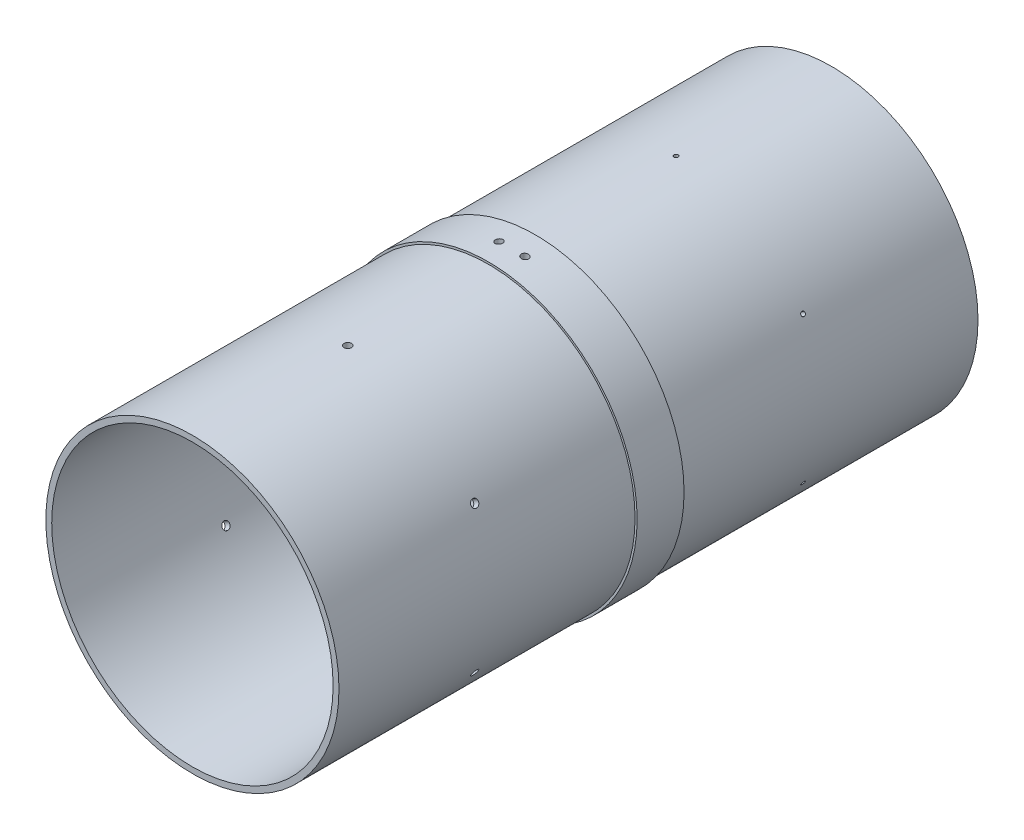
from build123d import *

# Parameters (mm, degrees)
SKETCH1_R                            = 79.375
SKETCH1_R_2                          = 76.2
BOSS_EXTRUDE1_DEPTH                  = 346.075
SKETCH2_R                            = 80.518
SKETCH2_R_2                          = 79.375
BOSS_EXTRUDE2_DEPTH                  = 12.7
F_5_32_0_15625_DIAMETER_HOLE1_REACH  = 393.49
F_5_32_0_15625_DIAMETER_HOLE1_BORE_R = 1.984375
F_4_40_TAPPED_HOLE1_REACH            = 391.637
F_4_40_TAPPED_HOLE1_BORE_R           = 1.1303
CIRPATTERN1_COUNT                    = 6
F_10_32_TAPPED_HOLE1_REACH           = 391.637
F_10_32_TAPPED_HOLE1_BORE_R          = 2.0193
CIRPATTERN2_COUNT                    = 6


with BuildPart() as part:
    # Sketch1 → Boss-Extrude1 (new body)
    with BuildSketch(Plane.XY):
        Circle(SKETCH1_R)
        Circle(SKETCH1_R_2, mode=Mode.SUBTRACT)
    extrude(amount=BOSS_EXTRUDE1_DEPTH)

    # Sketch2 → Boss-Extrude2 (add, symmetric)
    with BuildSketch(Plane.XY.offset(173.0375)):
        Circle(SKETCH2_R)
        Circle(SKETCH2_R_2, mode=Mode.SUBTRACT)
    extrude(amount=BOSS_EXTRUDE2_DEPTH, both=True)

    # 5/32 (0.15625) Diameter Hole1 bore → 5/32 (0.15625) Diameter Hole1 (cut, up to next)
    with BuildSketch(Plane(origin=(7.017606095, 80.211604701, 0), x_dir=(0, 0, 1), z_dir=(0.08715574274765156, 0.9961946980917461, 0)), mode=Mode.PRIVATE) as f_5_32_0_15625_diameter_hole1_sk1:
        with Locations((173.0375, 0)):
            Circle(F_5_32_0_15625_DIAMETER_HOLE1_BORE_R)
    f_5_32_0_15625_diameter_hole1_tool1 = extrude(f_5_32_0_15625_diameter_hole1_sk1.sketch, amount=-F_5_32_0_15625_DIAMETER_HOLE1_REACH, mode=Mode.PRIVATE) & part.part
    f_5_32_0_15625_diameter_hole1 = f_5_32_0_15625_diameter_hole1_tool1.solids().sort_by_distance((7.017606, 80.211605, 173.0375))[0]
    add(f_5_32_0_15625_diameter_hole1, mode=Mode.SUBTRACT)

    # Mirror1: 5/32 (0.15625) Diameter Hole1 across plane
    add(f_5_32_0_15625_diameter_hole1.mirror(Plane(origin=(0, 0, 0), x_dir=(0, 0, 1), z_dir=(1, 0, 0))), mode=Mode.SUBTRACT)

    # #4-40 Tapped Hole1 bore → #4-40 Tapped Hole1 (cut, up to next)
    with BuildSketch(Plane(origin=(0, 79.375, 0), x_dir=(1, 0, 0), z_dir=(0, 1, 0)), mode=Mode.PRIVATE) as f_4_40_tapped_hole1_sk1:
        with Locations((0, -84.1375)):
            Circle(F_4_40_TAPPED_HOLE1_BORE_R)
    f_4_40_tapped_hole1_tool1 = extrude(f_4_40_tapped_hole1_sk1.sketch, amount=-F_4_40_TAPPED_HOLE1_REACH, mode=Mode.PRIVATE) & part.part
    f_4_40_tapped_hole1 = f_4_40_tapped_hole1_tool1.solids().sort_by_distance((0, 79.375, 84.1375))[0]
    add(f_4_40_tapped_hole1, mode=Mode.SUBTRACT)

    # CirPattern1: #4-40 Tapped Hole1 ×6 about axis
    cirpattern1_axis = Axis((0, 0, 0), (0, 0, 1))
    for i in range(1, CIRPATTERN1_COUNT):
        add(f_4_40_tapped_hole1.rotate(cirpattern1_axis, i * 360 / CIRPATTERN1_COUNT), mode=Mode.SUBTRACT)

    # #10-32 Tapped Hole1 bore → #10-32 Tapped Hole1 (cut, up to next)
    with BuildSketch(Plane(origin=(0, 79.375, 0), x_dir=(1, 0, 0), z_dir=(0, 1, 0)), mode=Mode.PRIVATE) as f_10_32_tapped_hole1_sk1:
        with Locations((0, -261.9375)):
            Circle(F_10_32_TAPPED_HOLE1_BORE_R)
    f_10_32_tapped_hole1_tool1 = extrude(f_10_32_tapped_hole1_sk1.sketch, amount=-F_10_32_TAPPED_HOLE1_REACH, mode=Mode.PRIVATE) & part.part
    f_10_32_tapped_hole1 = f_10_32_tapped_hole1_tool1.solids().sort_by_distance((0, 79.375, 261.9375))[0]
    add(f_10_32_tapped_hole1, mode=Mode.SUBTRACT)

    # CirPattern2: #10-32 Tapped Hole1 ×6 about axis
    cirpattern2_axis = Axis((0, 0, 346.075), (0, 0, 1))
    for i in range(1, CIRPATTERN2_COUNT):
        add(f_10_32_tapped_hole1.rotate(cirpattern2_axis, i * 360 / CIRPATTERN2_COUNT), mode=Mode.SUBTRACT)


solid = part.part
